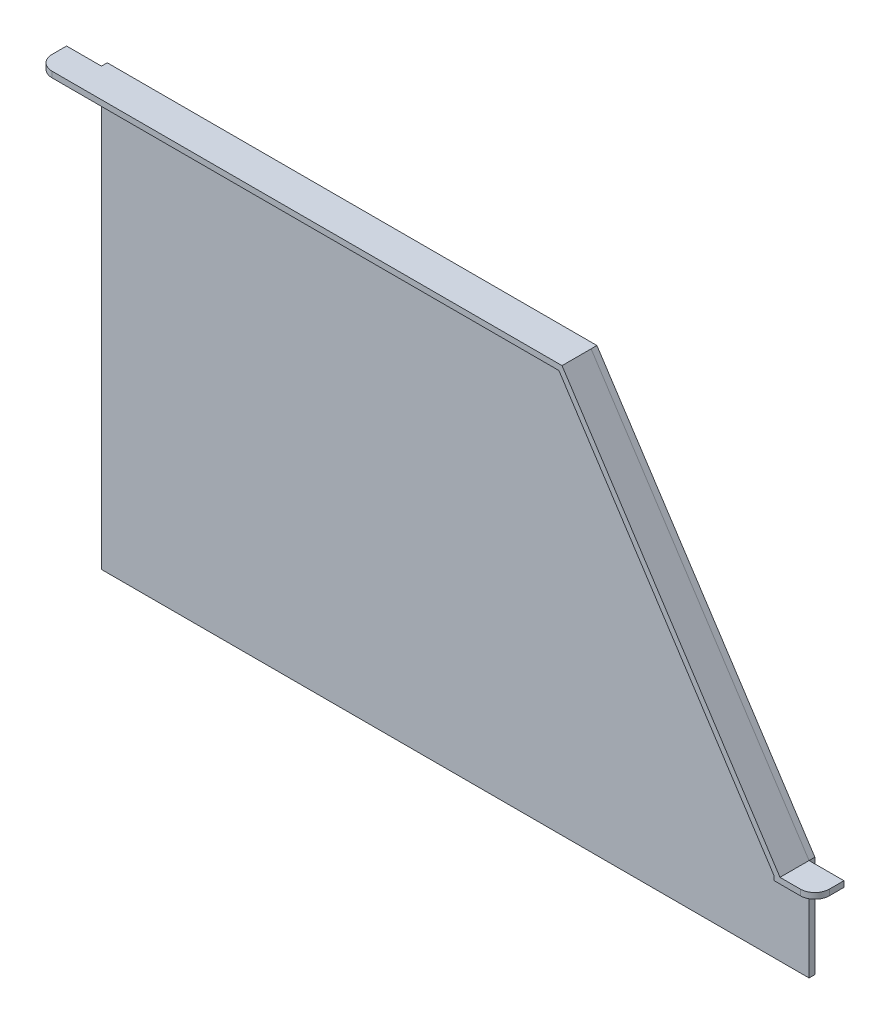
from build123d import *

# Parameters (mm, degrees)
BOSS_EXTRUDE1_DEPTH = 4
SKETCH7_W           = 336.995970405
SKETCH7_H           = 4
BOSS_EXTRUDE2_DEPTH = 20
BOSS_EXTRUDE3_DEPTH = 20
SKETCH9_W           = 4
SKETCH9_H           = 4
BOSS_EXTRUDE4_DEPTH = 20
SKETCH10_W          = 20
SKETCH10_H          = 4
BOSS_EXTRUDE5_DEPTH = 24
SKETCH12_W          = 20
SKETCH12_H          = 4
BOSS_EXTRUDE6_DEPTH = 24
FILLET1_R           = 10


with BuildPart() as part:
    # Sketch1 → Boss-Extrude1 (new body)
    with BuildSketch(Plane.XY):
        Polygon((0, 0), (0, 300), (337, 300), (487, 70), (487, 0), align=None)
    extrude(amount=BOSS_EXTRUDE1_DEPTH)

    # Sketch7 → Boss-Extrude2 (add)
    with BuildSketch(Plane.XY.offset(4)):
        with Locations((168.497985203, 298)):
            Rectangle(SKETCH7_W, SKETCH7_H)
    extrude(amount=BOSS_EXTRUDE2_DEPTH)

    # Sketch8 → Boss-Extrude3 (add)
    with BuildSketch(Plane.XY.offset(4)):
        Polygon((336.995970405, 300), (487, 70), (483.649584471, 67.814887695), (333.645554877, 297.814887695), align=None)
    extrude(amount=BOSS_EXTRUDE3_DEPTH)

    # Sketch9 → Boss-Extrude4 (add)
    with BuildSketch(Plane.XY.offset(4)):
        with Locations((485, 68)):
            Rectangle(SKETCH9_W, SKETCH9_H)
    extrude(amount=BOSS_EXTRUDE4_DEPTH)

    # Sketch10 → Boss-Extrude5 (add)
    with BuildSketch(Plane(origin=(487, 0, 0), x_dir=(0, 0, -1), z_dir=(1, 0, 0))):
        with Locations((-14, 68)):
            Rectangle(SKETCH10_W, SKETCH10_H)
    extrude(amount=BOSS_EXTRUDE5_DEPTH)

    # Sketch12 → Boss-Extrude6 (add)
    with BuildSketch(Plane.ZY):
        with Locations((14, 298)):
            Rectangle(SKETCH12_W, SKETCH12_H)
    extrude(amount=BOSS_EXTRUDE6_DEPTH)

    # Fillet1
    fillet1_edges = [part.edges().sort_by_distance(p)[0] for p in [
        (511, 68, 24),
        (-24, 298, 24),
    ]]
    fillet(fillet1_edges, radius=FILLET1_R)


solid = part.part
